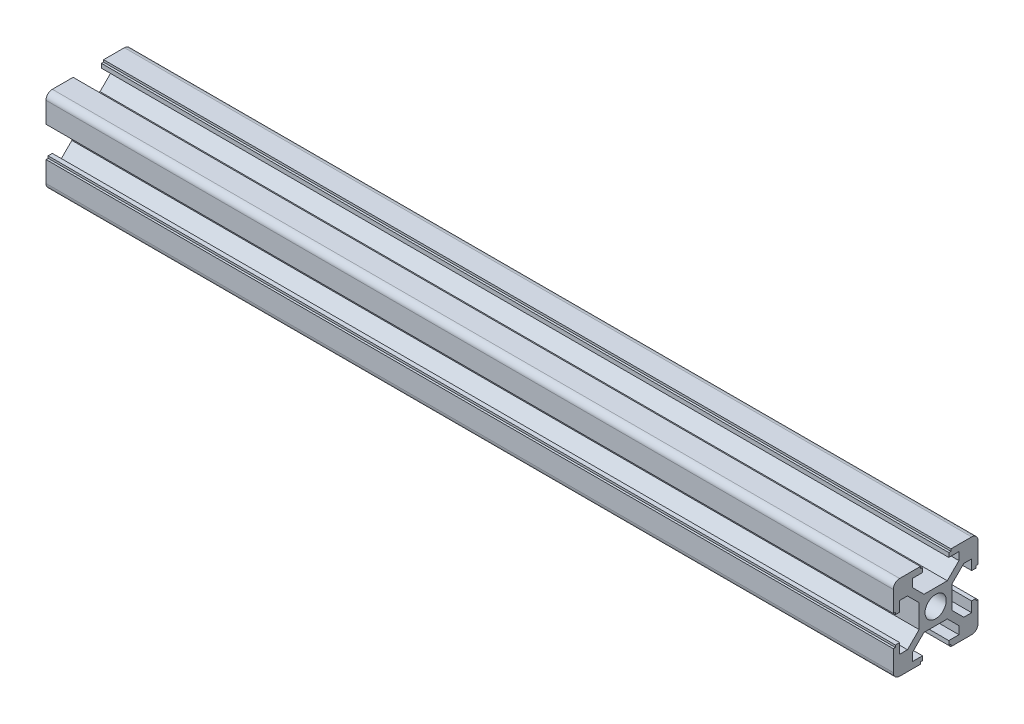
from build123d import *

# Parameters (mm, degrees)
SKETCH1_R                = 2.5
F_20_X_20_X_R1_5_1_DEPTH = 200


with BuildPart() as part:
    # Sketch1 → 铝型材 20 X 20 X R1.5(1) (new body)
    with BuildSketch(Plane(origin=(0, 0, 0), x_dir=(0, 0, -1), z_dir=(1, 0, 0))):
        with BuildLine():
            Line((-3.6, 10), (-3.6, 9.5))
            Line((-3.6, 9.5), (-3.1, 9.5))
            Line((-3.1, 9.5), (-3.1, 8.5))
            Line((-3.1, 8.5), (-5.5, 8.5))
            Line((-5.5, 8.5), (-5.5, 6.65))
            Line((-5.5, 6.65), (-2.75, 3.9))
            Line((-2.75, 3.9), (2.75, 3.9))
            Line((2.75, 3.9), (5.5, 6.65))
            Line((5.5, 6.65), (5.5, 8.5))
            Line((5.5, 8.5), (3.1, 8.5))
            Line((3.1, 8.5), (3.1, 9.5))
            Line((3.1, 9.5), (3.6, 9.5))
            Line((3.6, 9.5), (3.6, 10))
            Line((3.6, 10), (8.5, 10))
            ThreePointArc((8.5, 10), (9.560660172, 9.560660172), (10, 8.5))
            Line((10, 8.5), (10, 3.6))
            Line((10, 3.6), (9.5, 3.6))
            Line((9.5, 3.6), (9.5, 3.1))
            Line((9.5, 3.1), (8.5, 3.1))
            Line((8.5, 3.1), (8.5, 5.5))
            Line((8.5, 5.5), (6.65, 5.5))
            Line((6.65, 5.5), (3.9, 2.75))
            Line((3.9, 2.75), (3.9, -2.75))
            Line((3.9, -2.75), (6.65, -5.5))
            Line((6.65, -5.5), (8.5, -5.5))
            Line((8.5, -5.5), (8.5, -3.1))
            Line((8.5, -3.1), (9.5, -3.1))
            Line((9.5, -3.1), (9.5, -3.6))
            Line((9.5, -3.6), (10, -3.6))
            Line((10, -3.6), (10, -8.5))
            ThreePointArc((10, -8.5), (9.560660172, -9.560660172), (8.5, -10))
            Line((8.5, -10), (3.6, -10))
            Line((3.6, -10), (3.6, -9.5))
            Line((3.6, -9.5), (3.1, -9.5))
            Line((3.1, -9.5), (3.1, -8.5))
            Line((3.1, -8.5), (5.5, -8.5))
            Line((5.5, -8.5), (5.5, -6.65))
            Line((5.5, -6.65), (2.75, -3.9))
            Line((2.75, -3.9), (-2.75, -3.9))
            Line((-2.75, -3.9), (-5.5, -6.65))
            Line((-5.5, -6.65), (-5.5, -8.5))
            Line((-5.5, -8.5), (-3.1, -8.5))
            Line((-3.1, -8.5), (-3.1, -9.5))
            Line((-3.1, -9.5), (-3.6, -9.5))
            Line((-3.6, -9.5), (-3.6, -10))
            Line((-3.6, -10), (-8.5, -10))
            ThreePointArc((-8.5, -10), (-9.560660172, -9.560660172), (-10, -8.5))
            Line((-10, -8.5), (-10, -3.6))
            Line((-10, -3.6), (-9.5, -3.6))
            Line((-9.5, -3.6), (-9.5, -3.1))
            Line((-9.5, -3.1), (-8.5, -3.1))
            Line((-8.5, -3.1), (-8.5, -5.5))
            Line((-8.5, -5.5), (-6.65, -5.5))
            Line((-6.65, -5.5), (-3.9, -2.75))
            Line((-3.9, -2.75), (-3.9, 2.75))
            Line((-3.9, 2.75), (-6.65, 5.5))
            Line((-6.65, 5.5), (-8.5, 5.5))
            Line((-8.5, 5.5), (-8.5, 3.1))
            Line((-8.5, 3.1), (-9.5, 3.1))
            Line((-9.5, 3.1), (-9.5, 3.6))
            Line((-9.5, 3.6), (-10, 3.6))
            Line((-10, 3.6), (-10, 8.5))
            ThreePointArc((-10, 8.5), (-9.560660172, 9.560660172), (-8.5, 10))
            Line((-8.5, 10), (-3.6, 10))
        make_face()
        Circle(SKETCH1_R, mode=Mode.SUBTRACT)
    extrude(amount=F_20_X_20_X_R1_5_1_DEPTH)


solid = part.part
